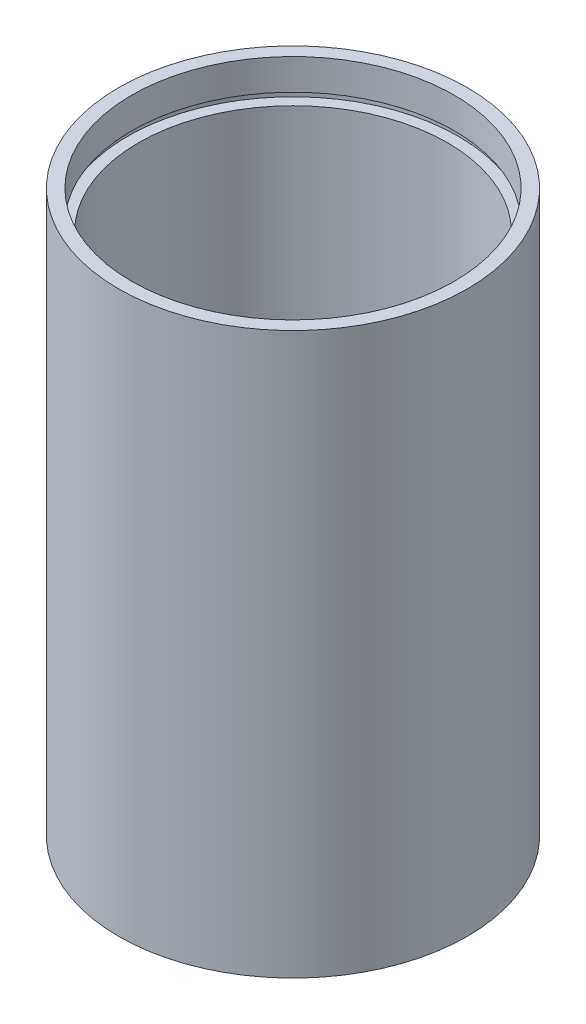
from build123d import *


with BuildPart() as part:
    # 草图1 → 旋转1 (revolve)
    with BuildSketch(Plane.XY, mode=Mode.PRIVATE) as revolve_1_sk:
        Polygon((25.4, 0), (25.4, 81.7), (23.5, 81.7), (23.5, 77.2), (24.1, 77.2), (24.1, 76.2), (22.5, 76.2), (22.5, 5.5), (24.1, 5.5), (24.1, 4.5), (23.5, 4.5), (23.5, 0), align=None)
    revolve(revolve_1_sk.sketch.rotate(Axis((0, 161.376166943, 0), (0, -1, 0)), 90), axis=Axis((0, 161.376166943, 0), (0, -1, 0)))  # turned: the seam where the file's is


solid = part.part
